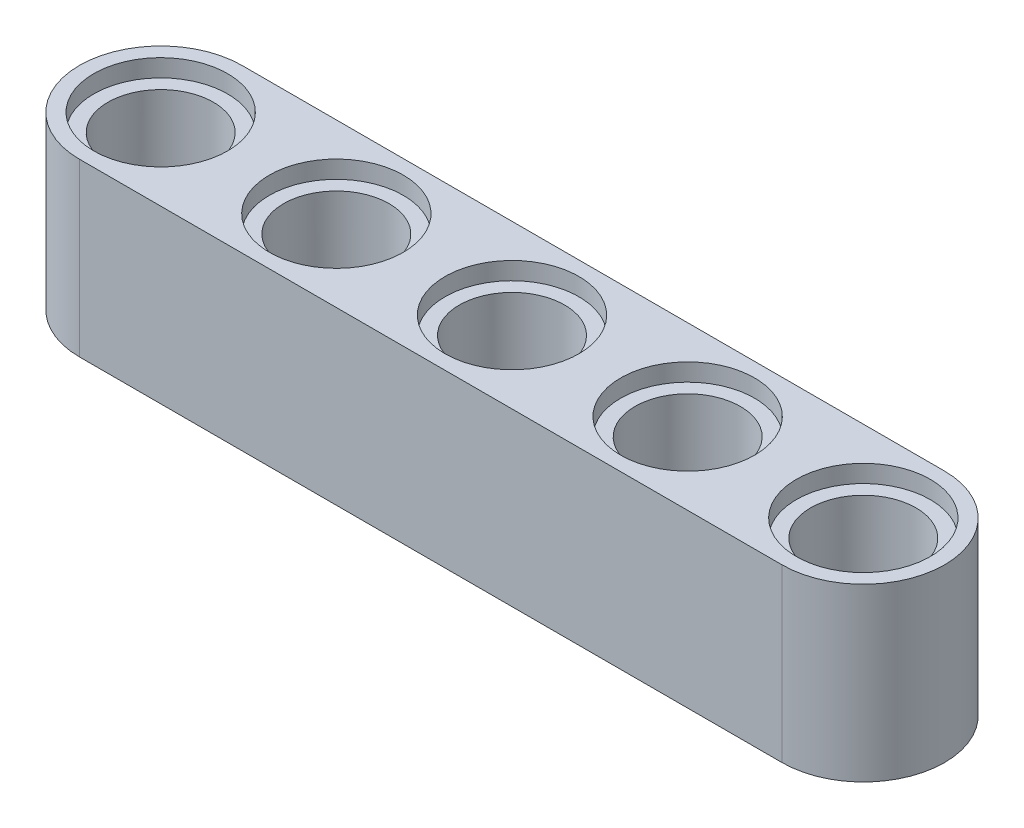
from build123d import *

# Parameters (mm, degrees)
BOSS_EXTRUDE3_DEPTH = 7.8
SKETCH2_R           = 2.4
CUT_EXTRUDE6_DEPTH  = 7.8
SKETCH3_R           = 3.05
CUT_EXTRUDE7_DEPTH  = 0.8
SKETCH4_R           = 3.05
CUT_EXTRUDE8_DEPTH  = 0.8


with BuildPart() as part:
    # Sketch1 → Boss-Extrude3 (new body)
    with BuildSketch(Plane(origin=(0, 0, 0), x_dir=(1, 0, 0), z_dir=(0, 1, 0))):
        with BuildLine():
            Line((-16, 3.7), (16, 3.7))
            ThreePointArc((16, 3.7), (19.7, 0), (16, -3.7))
            Line((16, -3.7), (0, -3.7))
            Line((0, -3.7), (-16, -3.7))
            ThreePointArc((-16, -3.7), (-19.7, 0), (-16, 3.7))
        make_face()
    extrude(amount=BOSS_EXTRUDE3_DEPTH)

    # Sketch2 → Cut-Extrude6 (cut)
    with BuildSketch(Plane(origin=(0, 7.8, 0), x_dir=(1, 0, 0), z_dir=(0, 1, 0))):
        Circle(SKETCH2_R)
        with Locations((8, 0)):
            Circle(SKETCH2_R)
        with Locations((16, 0)):
            Circle(SKETCH2_R)
        with Locations((-16, 0)):
            Circle(SKETCH2_R)
        with Locations((-8, 0)):
            Circle(SKETCH2_R)
    extrude(amount=-CUT_EXTRUDE6_DEPTH, mode=Mode.SUBTRACT)

    # Sketch3 → Cut-Extrude7 (cut)
    with BuildSketch(Plane(origin=(0, 7.8, 0), x_dir=(1, 0, 0), z_dir=(0, 1, 0))):
        Circle(SKETCH3_R)
        with Locations((8, 0)):
            Circle(SKETCH3_R)
        with Locations((16, 0)):
            Circle(SKETCH3_R)
        with Locations((-16, 0)):
            Circle(SKETCH3_R)
        with Locations((-8, 0)):
            Circle(SKETCH3_R)
    extrude(amount=-CUT_EXTRUDE7_DEPTH, mode=Mode.SUBTRACT)

    # Sketch4 → Cut-Extrude8 (cut)
    with BuildSketch(Plane.XZ):
        Circle(SKETCH4_R)
        with Locations((8, 0)):
            Circle(SKETCH4_R)
        with Locations((16, 0)):
            Circle(SKETCH4_R)
        with Locations((-16, 0)):
            Circle(SKETCH4_R)
        with Locations((-8, 0)):
            Circle(SKETCH4_R)
    extrude(amount=-CUT_EXTRUDE8_DEPTH, mode=Mode.SUBTRACT)


solid = part.part
